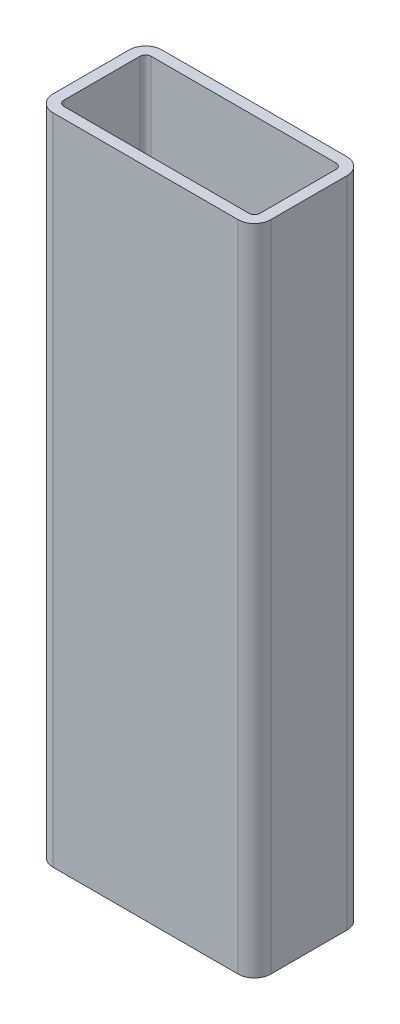
from build123d import *

# Parameters (mm, degrees)
EXTRUDE_1_DEPTH = 120


with BuildPart() as part:
    # Эскиз1 → Вытянуть-Тонкостенный1 (new body)
    with BuildSketch(Plane(origin=(0, 0, 0), x_dir=(1, 0, 0), z_dir=(0, 1, 0))):
        with BuildLine():
            Line((3, 0), (37, 0))
            ThreePointArc((37, 0), (39.121320344, 0.878679656), (40, 3))
            Line((40, 3), (40, 17))
            ThreePointArc((40, 17), (39.121320344, 19.121320344), (37, 20))
            Line((37, 20), (3, 20))
            ThreePointArc((3, 20), (0.878679656, 19.121320344), (0, 17))
            Line((0, 17), (0, 3))
            ThreePointArc((0, 3), (0.878679656, 0.878679656), (3, 0))
        make_face()
        with BuildLine():
            Line((3, 2), (37, 2))
            ThreePointArc((37, 2), (37.707106781, 2.292893219), (38, 3))
            Line((38, 3), (38, 17))
            ThreePointArc((38, 17), (37.707106781, 17.707106781), (37, 18))
            Line((37, 18), (3, 18))
            ThreePointArc((3, 18), (2.292893219, 17.707106781), (2, 17))
            Line((2, 17), (2, 3))
            ThreePointArc((2, 3), (2.292893219, 2.292893219), (3, 2))
        make_face(mode=Mode.SUBTRACT)
    extrude(amount=EXTRUDE_1_DEPTH)


solid = part.part
